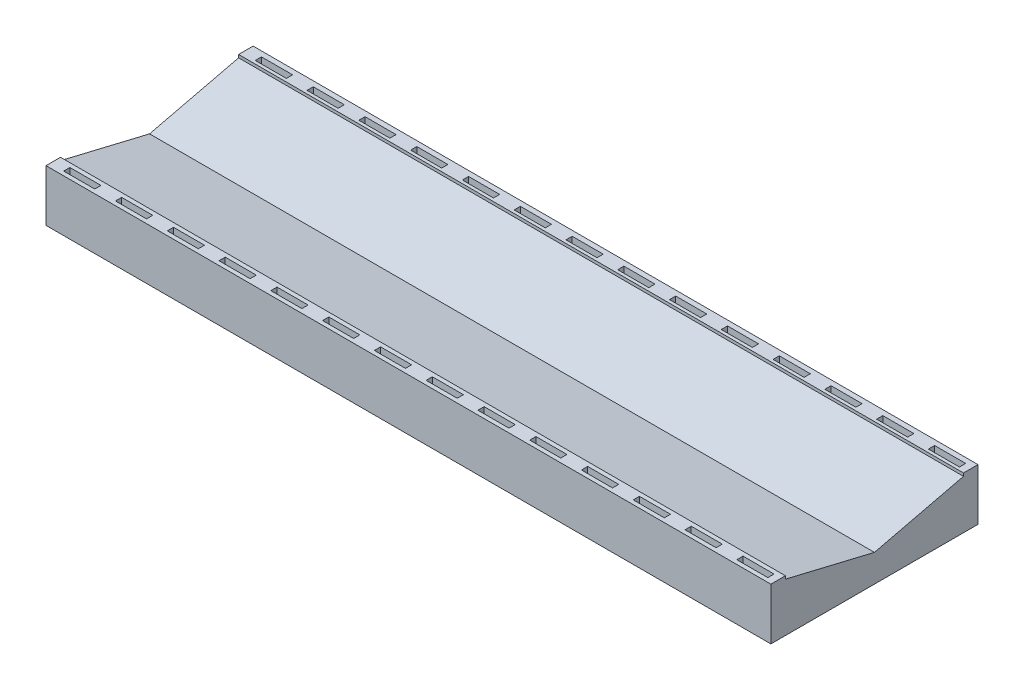
from build123d import *

# Parameters (mm, degrees)
SKETCH1_W            = 35
SKETCH1_H            = 10
BOSS_EXTRUDE1_DEPTH  = 2.5
SKETCH2_W            = 1.5
SKETCH2_H            = 0.3
CUT_EXTRUDE1_DEPTH   = 2
LPATTERN1_COUNT      = 14
LPATTERN1_PITCH      = 2.5
LPATTERN1_COUNT_DIR2 = 2
LPATTERN1_PITCH_DIR2 = 9.25
CUT_EXTRUDE2_DEPTH   = 37.486298798
CUT_EXTRUDE3_DEPTH   = 37.486298798


with BuildPart() as part:
    # Sketch1 → Boss-Extrude1 (new body)
    with BuildSketch(Plane(origin=(0, 0, 0), x_dir=(1, 0, 0), z_dir=(0, 1, 0))):
        with Locations((17.5, 5)):
            Rectangle(SKETCH1_W, SKETCH1_H)
    extrude(amount=BOSS_EXTRUDE1_DEPTH)

    # Sketch2 → Cut-Extrude1 (cut)
    with BuildSketch(Plane(origin=(0, 2.5, 0), x_dir=(1, 0, 0), z_dir=(0, 1, 0))):
        with Locations((1.404, 0.35)):
            Rectangle(SKETCH2_W, SKETCH2_H)
    cut_extrude1 = extrude(amount=-CUT_EXTRUDE1_DEPTH, mode=Mode.SUBTRACT)

    # LPattern1: Cut-Extrude1 14 × 2
    with Locations(*[(i * LPATTERN1_PITCH, 0, -j * LPATTERN1_PITCH_DIR2) for i in range(LPATTERN1_COUNT) for j in range(LPATTERN1_COUNT_DIR2) if (i, j) != (0, 0)]):
        add(cut_extrude1, mode=Mode.SUBTRACT)

    # Sketch3 → Cut-Extrude2 (cut, through all)
    with BuildSketch(Plane.ZY):
        Polygon((-0.701017802, 2.5), (-5, 2.5), (-5, 1.329177264), (-0.701017802, 2.35798372), align=None)
    extrude(amount=-CUT_EXTRUDE2_DEPTH, mode=Mode.SUBTRACT)

    # Sketch3_3 → Cut-Extrude3 (cut, through all)
    with BuildSketch(Plane.ZY):
        Polygon((-5, 2.5), (-9.298982198, 2.5), (-9.298982198, 2.35798372), (-5, 1.329177264), align=None)
    extrude(amount=-CUT_EXTRUDE3_DEPTH, mode=Mode.SUBTRACT)


solid = part.part
